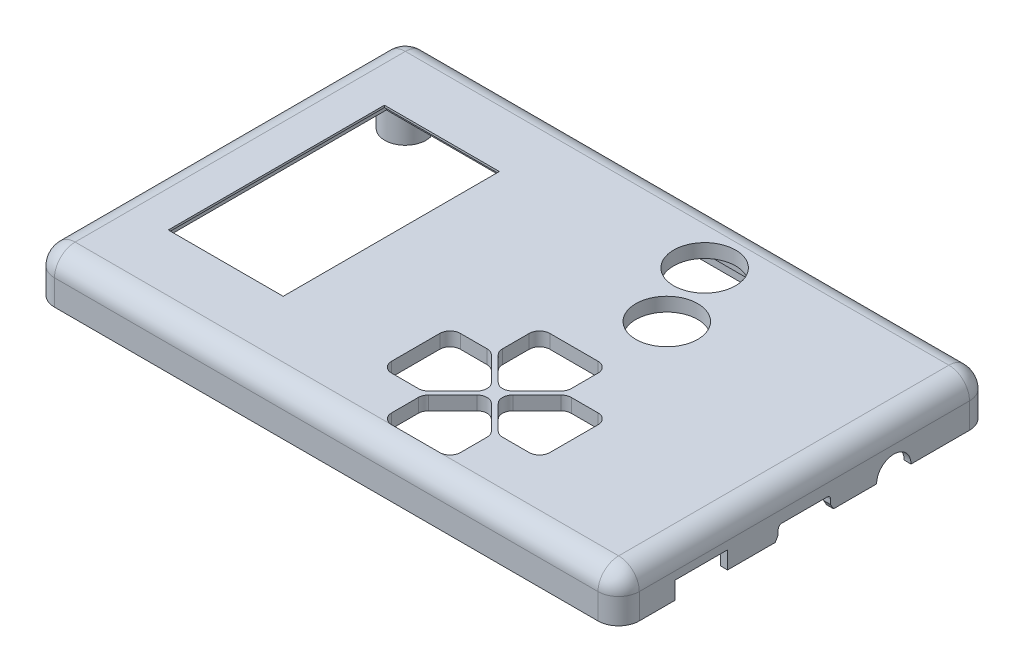
from build123d import *
from OCP.BRepFilletAPI import BRepFilletAPI_MakeChamfer

# Parameters (mm, degrees)
SKETCH_3_W                  = 85
SKETCH_3_H                  = 54
EXTRUDE_743_DEPTH           = 6.7
FILLET_794_R                = 3
CUT_EXTRUDE_1511_DEPTH      = 4.7
FILLET_1580_R               = 1
CUT_EXTRUDE_2543_DEPTH      = 2
CHAMFER_2604_SIZE           = 1
CHAMFER_2604_SIZE2          = 0.176326981
SKETCH_6_R                  = 2.5
CUT_EXTRUDE_2843_DEPTH      = 5
SKETCH_19_W                 = 7.62
SKETCH_19_H                 = 5.08
CUT_EXTRUDE_3017_DEPTH      = 10
SKETCH_31_W                 = 2.8
SKETCH_31_H                 = 1.2
CUT_EXTRUDE_8_DEPTH         = 10
CUT_EXTRUDE_5897_DEPTH      = 1.5
CUT_EXTRUDE_6361_REACH      = 52.732
SKETCH_8_W                  = 16.7
SKETCH_8_H                  = 31.42
SKETCH_40_W                 = 18.2
SKETCH_40_H                 = 33.5
CUT_EXTRUDE_16_DEPTH        = 0.2
SKETCH_42_W                 = 6.8
SKETCH_42_H                 = 16
CUT_EXTRUDE_17_DEPTH        = 0.1
DPAD_REACH                  = 52.795
DPAD_2_COUNT                = 4
SKETCH_A_R                  = 4.5
CUT_EXTRUDE_2_DEPTH         = 2
SKETCH_B_R                  = 4.5
CUT_EXTRUDE_3_DEPTH         = 2
CUT_EXTRUDE_10_DEPTH        = 10
SKETCH_34_W                 = 11.1
SKETCH_34_H                 = 1.1
CUT_EXTRUDE_11_DEPTH        = 10
CUT_EXTRUDE_13_DEPTH        = 10
CUT_EXTRUDE_14_DEPTH        = 1
SKETCH_39_W                 = 2.8
SKETCH_39_H                 = 1.2
CUT_EXTRUDE_15_DEPTH        = 10
SKETCH_43_R                 = 3
SKETCH_43_R_2               = 1.5
EXTRUDE_1_DEPTH             = 5.2
PATTERN_LINEAR_1_COUNT      = 2
PATTERN_LINEAR_1_PITCH      = 74
PATTERN_LINEAR_1_COUNT_DIR2 = 2
PATTERN_LINEAR_1_PITCH_DIR2 = 43


with BuildPart() as part:
    # 草图3 → Extrude 743 (new body)
    with BuildSketch(Plane(origin=(0, 0, 0), x_dir=(1, 0, 0), z_dir=(0, 1, 0))):
        Rectangle(SKETCH_3_W, SKETCH_3_H)
    extrude(amount=EXTRUDE_743_DEPTH)

    # Fillet 794
    fillet_794_edges = [part.edges().sort_by_distance(p)[0] for p in [
        (-42.5, 6.7, 0),
        (0, 6.7, 27),
        (42.5, 6.7, 0),
        (0, 6.7, -27),
        (42.5, 3.35, 27),
        (-42.5, 3.35, 27),
        (-42.5, 3.35, -27),
        (42.5, 3.35, -27),
    ]]
    fillet(fillet_794_edges, radius=FILLET_794_R)

    # 草图4 → Cut-Extrude 1511 (cut)
    with BuildSketch(Plane.XZ):
        with BuildLine():
            Line((-40.5, 24), (-40.5, -24))
            ThreePointArc((-40.5, -24), (-40.207106781, -24.707106781), (-39.5, -25))
            Line((-39.5, -25), (39.5, -25))
            ThreePointArc((39.5, -25), (40.207106781, -24.707106781), (40.5, -24))
            Line((40.5, -24), (40.5, 24))
            ThreePointArc((40.5, 24), (40.207106781, 24.707106781), (39.5, 25))
            Line((39.5, 25), (-39.5, 25))
            ThreePointArc((-39.5, 25), (-40.207106781, 24.707106781), (-40.5, 24))
        make_face()
    extrude(amount=-CUT_EXTRUDE_1511_DEPTH, mode=Mode.SUBTRACT)

    # Fillet 1580
    fillet_1580_edges = [part.edges().sort_by_distance(p)[0] for p in [
        (0, 4.7, -25),
        (40.207106781, 4.7, -24.707106781),
        (40.5, 4.7, 0),
        (40.207106781, 4.7, 24.707106781),
        (0, 4.7, 25),
        (-40.207106781, 4.7, 24.707106781),
        (-40.5, 4.7, 0),
        (-40.207106781, 4.7, -24.707106781),
    ]]
    fillet(fillet_1580_edges, radius=FILLET_1580_R)

    # 草图5 → Cut-Extrude 2543 (cut)
    with BuildSketch(Plane.XZ):
        with BuildLine():
            Line((-41.5, 24), (-41.5, -24))
            ThreePointArc((-41.5, -24), (-40.914213562, -25.414213562), (-39.5, -26))
            Line((-39.5, -26), (39.5, -26))
            ThreePointArc((39.5, -26), (40.914213562, -25.414213562), (41.5, -24))
            Line((41.5, -24), (41.5, 24))
            ThreePointArc((41.5, 24), (40.914213562, 25.414213562), (39.5, 26))
            Line((39.5, 26), (-39.5, 26))
            ThreePointArc((-39.5, 26), (-40.914213562, 25.414213562), (-41.5, 24))
        make_face()
        with BuildLine():
            Line((-40.5, 24), (-40.5, -24))
            ThreePointArc((-40.5, -24), (-40.207106781, -24.707106781), (-39.5, -25))
            Line((-39.5, -25), (39.5, -25))
            ThreePointArc((39.5, -25), (40.207106781, -24.707106781), (40.5, -24))
            Line((40.5, -24), (40.5, 24))
            ThreePointArc((40.5, 24), (40.207106781, 24.707106781), (39.5, 25))
            Line((39.5, 25), (-39.5, 25))
            ThreePointArc((-39.5, 25), (-40.207106781, 24.707106781), (-40.5, 24))
        make_face(mode=Mode.SUBTRACT)
    extrude(amount=-CUT_EXTRUDE_2543_DEPTH, mode=Mode.SUBTRACT)

    # Chamfer 2604: one chamfer whose edges measure the first distance from different faces: ONE call of the kernel's chamfer builder (chamfer() names one face for all edges)
    chamfer_2604_edges_1 = [part.edges().sort_by_distance(p)[0] for p in [
        (0, 2, 26),
    ]]
    chamfer_2604_side_1 = [part.faces().sort_by_distance(p)[0] for p in [
        (0, 1, 26),
    ]]
    chamfer_2604_edges_2 = [part.edges().sort_by_distance(p)[0] for p in [
        (40.914213562, 2, 25.414213562),
    ]]
    chamfer_2604_side_2 = [part.faces().sort_by_distance(p)[0] for p in [
        (40.914213562, 1, 25.414213562),
    ]]
    chamfer_2604_edges_3 = [part.edges().sort_by_distance(p)[0] for p in [
        (41.5, 2, 0),
    ]]
    chamfer_2604_side_3 = [part.faces().sort_by_distance(p)[0] for p in [
        (41.5, 1, 0),
    ]]
    chamfer_2604_edges_4 = [part.edges().sort_by_distance(p)[0] for p in [
        (40.914213562, 2, -25.414213562),
    ]]
    chamfer_2604_side_4 = [part.faces().sort_by_distance(p)[0] for p in [
        (40.914213562, 1, -25.414213562),
    ]]
    chamfer_2604_edges_5 = [part.edges().sort_by_distance(p)[0] for p in [
        (0, 2, -26),
    ]]
    chamfer_2604_side_5 = [part.faces().sort_by_distance(p)[0] for p in [
        (0, 1, -26),
    ]]
    chamfer_2604_edges_6 = [part.edges().sort_by_distance(p)[0] for p in [
        (-40.914213562, 2, -25.414213562),
    ]]
    chamfer_2604_side_6 = [part.faces().sort_by_distance(p)[0] for p in [
        (-40.914213562, 1, -25.414213562),
    ]]
    chamfer_2604_edges_7 = [part.edges().sort_by_distance(p)[0] for p in [
        (-41.5, 2, 0),
    ]]
    chamfer_2604_side_7 = [part.faces().sort_by_distance(p)[0] for p in [
        (-41.5, 1, 0),
    ]]
    chamfer_2604_edges_8 = [part.edges().sort_by_distance(p)[0] for p in [
        (-40.914213562, 2, 25.414213562),
    ]]
    chamfer_2604_side_8 = [part.faces().sort_by_distance(p)[0] for p in [
        (-40.914213562, 1, 25.414213562),
    ]]
    chamfer_2604 = BRepFilletAPI_MakeChamfer(part.part.solid().wrapped)
    for e in chamfer_2604_edges_1:
        chamfer_2604.Add(CHAMFER_2604_SIZE, CHAMFER_2604_SIZE2, e.wrapped, chamfer_2604_side_1[0].wrapped)  # the first distance lies on this face
    for e in chamfer_2604_edges_2:
        chamfer_2604.Add(CHAMFER_2604_SIZE, CHAMFER_2604_SIZE2, e.wrapped, chamfer_2604_side_2[0].wrapped)  # the first distance lies on this face
    for e in chamfer_2604_edges_3:
        chamfer_2604.Add(CHAMFER_2604_SIZE, CHAMFER_2604_SIZE2, e.wrapped, chamfer_2604_side_3[0].wrapped)  # the first distance lies on this face
    for e in chamfer_2604_edges_4:
        chamfer_2604.Add(CHAMFER_2604_SIZE, CHAMFER_2604_SIZE2, e.wrapped, chamfer_2604_side_4[0].wrapped)  # the first distance lies on this face
    for e in chamfer_2604_edges_5:
        chamfer_2604.Add(CHAMFER_2604_SIZE, CHAMFER_2604_SIZE2, e.wrapped, chamfer_2604_side_5[0].wrapped)  # the first distance lies on this face
    for e in chamfer_2604_edges_6:
        chamfer_2604.Add(CHAMFER_2604_SIZE, CHAMFER_2604_SIZE2, e.wrapped, chamfer_2604_side_6[0].wrapped)  # the first distance lies on this face
    for e in chamfer_2604_edges_7:
        chamfer_2604.Add(CHAMFER_2604_SIZE, CHAMFER_2604_SIZE2, e.wrapped, chamfer_2604_side_7[0].wrapped)  # the first distance lies on this face
    for e in chamfer_2604_edges_8:
        chamfer_2604.Add(CHAMFER_2604_SIZE, CHAMFER_2604_SIZE2, e.wrapped, chamfer_2604_side_8[0].wrapped)  # the first distance lies on this face
    add(Compound.cast(chamfer_2604.Shape()), mode=Mode.REPLACE)

    # 草图6 → Cut-Extrude 2843 (cut)
    with BuildSketch(Plane(origin=(42.5, -7.5, 0), x_dir=(0, 0, -1), z_dir=(1, 0, 0))):
        with Locations((13, 7.5)):
            Circle(SKETCH_6_R)
    extrude(amount=-CUT_EXTRUDE_2843_DEPTH, mode=Mode.SUBTRACT)

    # 草图19 → Cut-Extrude 3017 (cut)
    with BuildSketch(Plane(origin=(42.5, -7.5, 0), x_dir=(0, 0, -1), z_dir=(1, 0, 0))):
        with Locations((-14.978380782, 7.5)):
            Rectangle(SKETCH_19_W, SKETCH_19_H)
    extrude(amount=-CUT_EXTRUDE_3017_DEPTH, mode=Mode.SUBTRACT)

    # 草图31 → 切除-拉伸8 (cut)
    with BuildSketch(Plane(origin=(-42.5, -7.5, 0), x_dir=(0, 0, 1), z_dir=(-1, 0, 0))):
        with Locations((15.5, 7.6)):
            Rectangle(SKETCH_31_W, SKETCH_31_H)
    extrude(amount=-CUT_EXTRUDE_8_DEPTH, mode=Mode.SUBTRACT)

    # 草图7 → Cut-Extrude 5897 (cut)
    with BuildSketch(Plane.XZ.offset(-4.7)):
        Polygon((-12.5, 17.25), (-12.5, 6.5), (-9.5, 6.5), (-9.5, -6.5), (-12.5, -6.5), (-12.5, -17.25), (-35.5, -17.25), (-35.5, 17.25), align=None)
    extrude(amount=-CUT_EXTRUDE_5897_DEPTH, mode=Mode.SUBTRACT)

    # 草图8 → Cut-Extrude 6361 (cut, up to next)
    with BuildSketch(Plane.XZ.offset(-6.2), mode=Mode.PRIVATE) as cut_extrude_6361_sk1:
        with Locations((-25.9, 0)):
            Rectangle(SKETCH_8_W, SKETCH_8_H)
    cut_extrude_6361_tool1 = extrude(cut_extrude_6361_sk1.sketch, amount=-CUT_EXTRUDE_6361_REACH, mode=Mode.PRIVATE) & part.part
    add(cut_extrude_6361_tool1.solids().sort_by_distance((-25.9, 6.2, 0))[0], mode=Mode.SUBTRACT)

    # 草图40 → 切除-拉伸16 (cut)
    with BuildSketch(Plane.XZ.offset(-6.2)):
        with Locations((-25.9, 0)):
            Rectangle(SKETCH_40_W, SKETCH_40_H)
    extrude(amount=-CUT_EXTRUDE_16_DEPTH, mode=Mode.SUBTRACT)

    # 草图42 → 切除-拉伸17 (cut)
    with BuildSketch(Plane.XZ.offset(-6.2)):
        with Locations((-12.9, 0)):
            Rectangle(SKETCH_42_W, SKETCH_42_H)
    extrude(amount=-CUT_EXTRUDE_17_DEPTH, mode=Mode.SUBTRACT)

    # 草图11 → DPad (cut, up to next)
    with BuildSketch(Plane(origin=(0, 6.7, 0), x_dir=(1, 0, 0), z_dir=(0, 1, 0)), mode=Mode.PRIVATE) as dpad_sk1:
        with BuildLine():
            Line((4.939339828, -17.060660172), (8.439339828, -13.560660172))
            ThreePointArc((8.439339828, -13.560660172), (8.878679656, -12.5), (8.439339828, -11.439339828))
            Line((8.439339828, -11.439339828), (4.939339828, -7.939339828))
            ThreePointArc((4.939339828, -7.939339828), (4.452704805, -7.614180701), (3.878679656, -7.5))
            Line((3.878679656, -7.5), (0, -7.5))
            ThreePointArc((0, -7.5), (-1.060660172, -7.939339828), (-1.5, -9))
            Line((-1.5, -9), (-1.5, -16))
            ThreePointArc((-1.5, -16), (-1.060660172, -17.060660172), (0, -17.5))
            Line((0, -17.5), (3.878679656, -17.5))
            ThreePointArc((3.878679656, -17.5), (4.452704805, -17.385819299), (4.939339828, -17.060660172))
        make_face()
    dpad_tool1 = extrude(dpad_sk1.sketch, amount=-DPAD_REACH, mode=Mode.PRIVATE) & part.part
    dpad = dpad_tool1.solids().sort_by_distance((2.881821, 6.7, 12.5))[0]
    add(dpad, mode=Mode.SUBTRACT)

    # DPad 2: DPad ×4 about axis
    dpad_2_axis = Axis((10, 0, 12.5), (0, 1, 0))
    for i in range(1, DPAD_2_COUNT):
        add(dpad.rotate(dpad_2_axis, i * 360 / DPAD_2_COUNT), mode=Mode.SUBTRACT)

    # A键 → 切除-拉伸2 (cut)
    with BuildSketch(Plane(origin=(0, 6.7, 0), x_dir=(1, 0, 0), z_dir=(0, 1, 0))):
        with Locations(Location((13.5, 9, 0), (0, 0, 270))):
            Circle(SKETCH_A_R)
    extrude(amount=-CUT_EXTRUDE_2_DEPTH, mode=Mode.SUBTRACT)

    # B键 → 切除-拉伸3 (cut)
    with BuildSketch(Plane(origin=(0, 6.7, 0), x_dir=(1, 0, 0), z_dir=(0, 1, 0))):
        with Locations(Location((9.5, 18.5, 0), (0, 0, 270))):
            Circle(SKETCH_B_R)
    extrude(amount=-CUT_EXTRUDE_3_DEPTH, mode=Mode.SUBTRACT)

    # 草图33 → 切除-拉伸10 (cut)
    with BuildSketch(Plane(origin=(42.5, -7.5, 0), x_dir=(0, 0, -1), z_dir=(1, 0, 0))):
        with BuildLine():
            Line((3.8, 8.257106781), (3.8, 8.95))
            ThreePointArc((3.8, 8.95), (3.653553391, 9.303553391), (3.3, 9.45))
            Line((3.3, 9.45), (-3.3, 9.45))
            ThreePointArc((-3.3, 9.45), (-3.653553391, 9.303553391), (-3.8, 8.95))
            Line((-3.8, 8.95), (-3.8, 8.257106781))
            ThreePointArc((-3.8, 8.257106781), (-3.761939766, 8.065765065), (-3.653553391, 7.903553391))
            Line((-3.653553391, 7.903553391), (-2.746446609, 6.996446609))
            ThreePointArc((-2.746446609, 6.996446609), (-2.584234935, 6.888060234), (-2.392893219, 6.85))
            Line((-2.392893219, 6.85), (2.392893219, 6.85))
            ThreePointArc((2.392893219, 6.85), (2.584234935, 6.888060234), (2.746446609, 6.996446609))
            Line((2.746446609, 6.996446609), (3.653553391, 7.903553391))
            ThreePointArc((3.653553391, 7.903553391), (3.761939766, 8.065765065), (3.8, 8.257106781))
        make_face()
    extrude(amount=-CUT_EXTRUDE_10_DEPTH, mode=Mode.SUBTRACT)

    # 草图34 → 切除-拉伸11 (cut)
    with BuildSketch(Plane(origin=(-42.5, -7.5, 0), x_dir=(0, 0, 1), z_dir=(-1, 0, 0))):
        with Locations((0, 8.225)):
            Rectangle(SKETCH_34_W, SKETCH_34_H)
    extrude(amount=-CUT_EXTRUDE_11_DEPTH, mode=Mode.SUBTRACT)

    # 草图37 → 切除-拉伸13 (cut)
    with BuildSketch(Plane(origin=(42.5, 0, 0), x_dir=(0, 0, -1), z_dir=(1, 0, 0))):
        with BuildLine():
            Line((-3.8, 0.757106781), (-4.237115804, 0))
            Line((-4.237115804, 0), (-3.25, 0))
            Line((-3.25, 0), (-3.653553391, 0.403553391))
            ThreePointArc((-3.653553391, 0.403553391), (-3.761939766, 0.565765065), (-3.8, 0.757106781))
        make_face()
        with BuildLine():
            Line((3.8, 0.757106781), (4.237115804, 0))
            Line((4.237115804, 0), (3.25, 0))
            Line((3.25, 0), (3.653553391, 0.403553391))
            ThreePointArc((3.653553391, 0.403553391), (3.761939766, 0.565765065), (3.8, 0.757106781))
        make_face()
    extrude(amount=-CUT_EXTRUDE_13_DEPTH, mode=Mode.SUBTRACT)

    # 草图38 → 切除-拉伸14 (cut)
    with BuildSketch(Plane.ZY.offset(42.5)):
        Polygon((-5.55, 0.175), (-5.651036297, 0), (5.651036297, 0), (5.55, 0.175), align=None)
    extrude(amount=-CUT_EXTRUDE_14_DEPTH, mode=Mode.SUBTRACT)

    # 草图39 → 切除-拉伸15 (cut)
    with BuildSketch(Plane(origin=(0, -7.5, -27), x_dir=(-1, 0, 0), z_dir=(0, 0, -1))):
        with Locations((31, 7.6)):
            Rectangle(SKETCH_39_W, SKETCH_39_H)
    extrude(amount=-CUT_EXTRUDE_15_DEPTH, mode=Mode.SUBTRACT)

    # 草图43 → 凸台-拉伸1 (add)
    with BuildSketch(Plane.XZ.offset(-4.7)):
        with Locations(Location((-37, 21.5, 0), (0, 0, 123.557309762))):
            Circle(SKETCH_43_R)
        with Locations(Location((-37, 21.5, 0), (0, 0, 270))):
            Circle(SKETCH_43_R_2, mode=Mode.SUBTRACT)
    extrude_1 = extrude(amount=EXTRUDE_1_DEPTH)

    # 阵列(线性)1: Extrude 1 2 × 2
    with Locations(*[(i * PATTERN_LINEAR_1_PITCH, 0, -j * PATTERN_LINEAR_1_PITCH_DIR2) for i in range(PATTERN_LINEAR_1_COUNT) for j in range(PATTERN_LINEAR_1_COUNT_DIR2) if (i, j) != (0, 0)]):
        add(extrude_1)


solid = part.part
